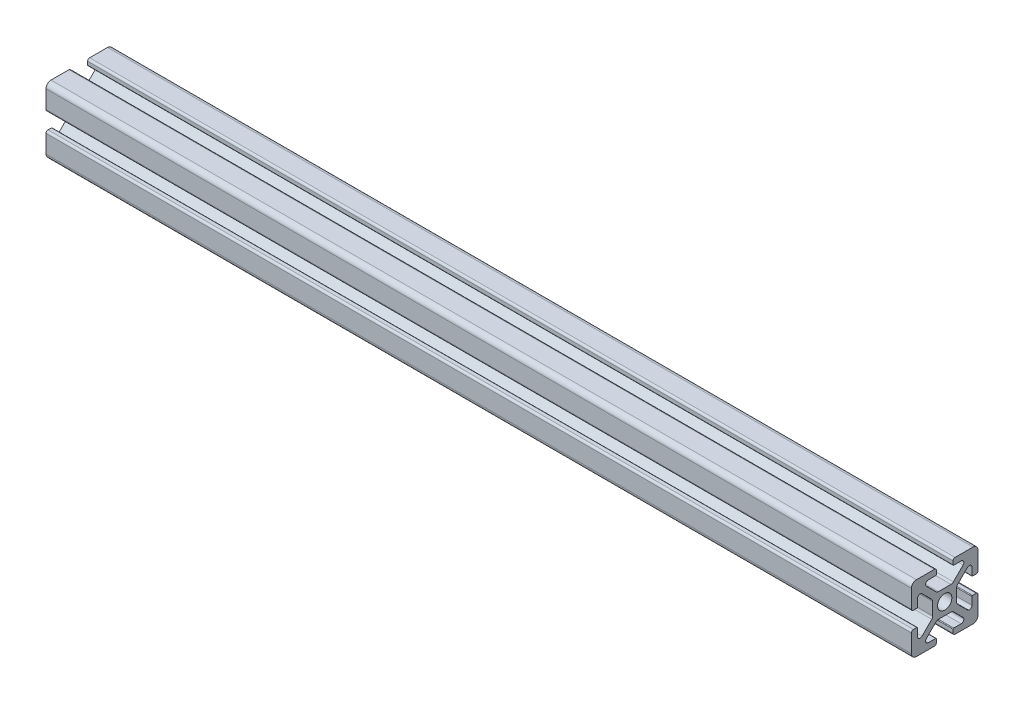
from build123d import *

# Parameters (mm, degrees)
BOSS_EXTRUDE1_DEPTH = 260


with BuildPart() as part:
    # Sketch3 → Boss-Extrude1 (new body)
    with BuildSketch(Plane(origin=(0, 0, 0), x_dir=(0, 0, -1), z_dir=(1, 0, 0))):
        with BuildLine():
            Line((-5.515685425, 6.807463915), (-2.601114729, 3.892893219))
            ThreePointArc((-2.601114729, 3.892893219), (-2.27669138, 3.676120467), (-1.894007948, 3.6))
            Line((-1.894007948, 3.6), (0, 3.6))
            Line((0, 3.6), (0, 2.15))
            ThreePointArc((0, 2.15), (-1.52027958, 1.52027958), (-2.15, 0))
            Line((-2.15, 0), (-3.6, 0))
            Line((-3.6, 0), (-3.6, 1.894007948))
            ThreePointArc((-3.6, 1.894007948), (-3.676120467, 2.27669138), (-3.892893219, 2.601114729))
            Line((-3.892893219, 2.601114729), (-6.807463915, 5.515685425))
            ThreePointArc((-6.807463915, 5.515685425), (-7.679296086, 5.689103626), (-8.17314934, 4.95))
            Line((-8.17314934, 4.95), (-8.17314934, 2.7))
            ThreePointArc((-8.17314934, 2.7), (-8.231727984, 2.558578644), (-8.37314934, 2.5))
            Line((-8.37314934, 2.5), (-9.4, 2.5))
            ThreePointArc((-9.4, 2.5), (-9.824264069, 2.675735931), (-10, 3.1))
            Line((-10, 3.1), (-10, 8.5))
            ThreePointArc((-10, 8.5), (-9.560660172, 9.560660172), (-8.5, 10))
            Line((-8.5, 10), (-3.1, 10))
            ThreePointArc((-3.1, 10), (-2.675735931, 9.824264069), (-2.5, 9.4))
            Line((-2.5, 9.4), (-2.5, 8.37314934))
            ThreePointArc((-2.5, 8.37314934), (-2.558578644, 8.231727984), (-2.7, 8.17314934))
            Line((-2.7, 8.17314934), (-4.95, 8.17314934))
            ThreePointArc((-4.95, 8.17314934), (-5.689103626, 7.679296086), (-5.515685425, 6.807463915))
        make_face()
    extrude(amount=-BOSS_EXTRUDE1_DEPTH)

    # Mirror1: part across plane


with BuildPart() as part_1:
    add(part.part)
    add(part.part.mirror(Plane.ZX))

    # Mirror2: part across plane


with BuildPart() as part_2:
    add(part_1.part)
    add(part_1.part.mirror(Plane.XY))


solid = part_2.part
